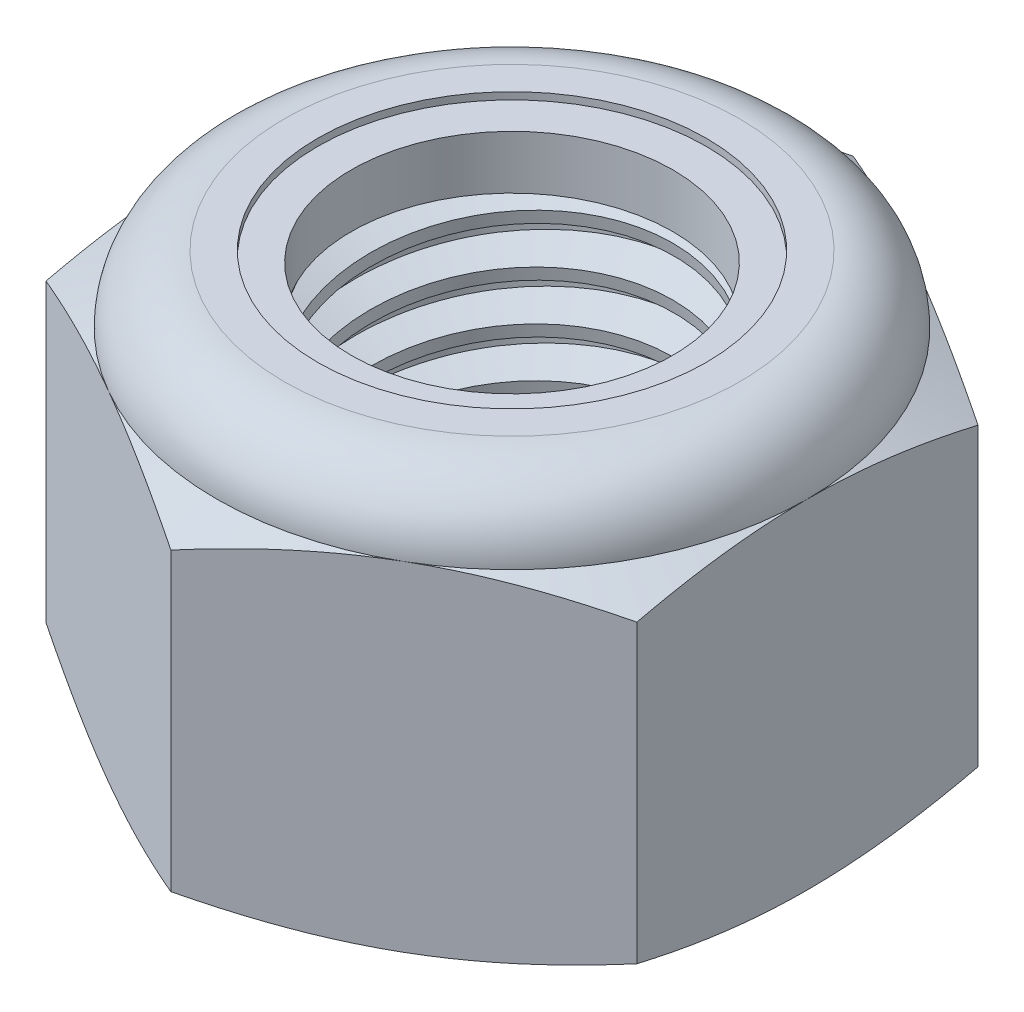
from build123d import *

# Parameters (mm, degrees)
EXTRUDE1_DEPTH      = 8.73125
SKETCH2_W           = 3.9624
SKETCH2_H           = 8.73125
LPATTERN1_COUNT     = 8
LPATTERN1_PITCH     = 1.058333333
LPATTERN1_COL_COUNT = 2
LPATTERN1_COL_PITCH = 1.058333333


with BuildPart() as part:
    # Sketch1 → Extrude1 (new body)
    with BuildSketch(Plane(origin=(0, 0, 0), x_dir=(1, 0, 0), z_dir=(0, 1, 0))):
        Polygon((0, 7.332348419), (-6.35, 3.666174209), (-6.35, -3.666174209), (0, -7.332348419), (6.35, -3.666174209), (6.35, 3.666174209), align=None)
    extrude(amount=EXTRUDE1_DEPTH)

    # Sketch4 → Cut-Revolve2 (revolve, cut)
    with BuildSketch(Plane(origin=(0, 0, 0), x_dir=(0, 0, -1), z_dir=(1, 0, 0))):
        Polygon((0, 8.73125), (3.9624, 8.73125), (3.4558921, 8.495061487), (3.4558921, 0.236188513), (3.9624, 0), (0, 0), align=None)
    revolve(axis=Axis((0, 8.73125, 0), (0, 1, 0)), mode=Mode.SUBTRACT)


with BuildPart() as body_2:
    # Sketch2 → Revolve1 (revolve)
    with BuildSketch(Plane(origin=(0, 0, 0), x_dir=(0, 0, -1), z_dir=(1, 0, 0))):
        with Locations((1.9812, 4.365625)):
            Rectangle(SKETCH2_W, SKETCH2_H)
    revolve(axis=Axis((0, -3.9624, 0), (0, 1, 0)))

    # Sketch3 → Cut-Revolve1 (revolve, cut)
    with BuildSketch(Plane(origin=(0, 0, 0), x_dir=(0, 0, -1), z_dir=(1, 0, 0))):
        Polygon((3.979911688, 8.600122482), (4.102493502, 7.682229859), (3.490915476, 7.934220821), (3.4558921, 8.196475856), align=None)
    cut_revolve1 = revolve(axis=Axis((0, 8.73125, 0.150876649), (0, -0.991200133, -0.132371813)), mode=Mode.SUBTRACT)

    # LPattern1: Cut-Revolve1 ×8
    with Locations(*[(0, -i * LPATTERN1_PITCH, 0) for i in range(1, LPATTERN1_COUNT)]):
        add(cut_revolve1, mode=Mode.SUBTRACT)

    # LPattern1 col: Cut-Revolve1 ×2
    with Locations(*[(0, i * LPATTERN1_COL_PITCH, 0) for i in range(1, LPATTERN1_COL_COUNT)]):
        add(cut_revolve1, mode=Mode.SUBTRACT)


with BuildPart() as part_1:
    add(part.part)

    # Combine1: cut body 2
    add(body_2.part, mode=Mode.SUBTRACT)

    # Sketch5 → Cut-Revolve3 (revolve, cut)
    with BuildSketch(Plane(origin=(0, 0, 0), x_dir=(0, 0, -1), z_dir=(1, 0, 0))):
        with BuildLine():
            Line((0, 0), (6.35, 0))
            Line((6.35, 0), (7.332348419, 0.458076591))
            Line((7.332348419, 0.458076591), (7.332348419, 6.817965076))
            Line((7.332348419, 6.817965076), (6.35, 7.276041667))
            ThreePointArc((6.35, 7.276041667), (5.923779347, 8.305029347), (4.894791667, 8.73125))
            Line((4.894791667, 8.73125), (4.894791667, 10.00125))
            Line((4.894791667, 10.00125), (8.602348419, 10.00125))
            Line((8.602348419, 10.00125), (8.602348419, -1.27))
            Line((8.602348419, -1.27), (0, -1.27))
            Line((0, -1.27), (0, 0))
        make_face()
    revolve(axis=Axis((0, 0, 0), (0, 1, 0)), mode=Mode.SUBTRACT)

    # Sketch6 → Cut-Revolve4 (revolve, cut)
    with BuildSketch(Plane(origin=(0, 0, 0), x_dir=(0, 0, -1), z_dir=(1, 0, 0))):
        with BuildLine():
            Line((0, 7.276041667), (6.1976, 7.276041667))
            ThreePointArc((6.1976, 7.276041667), (5.816016274, 8.197266274), (4.894791667, 8.57885))
            Line((4.894791667, 8.57885), (4.175341883, 8.57885))
            Line((4.175341883, 8.57885), (4.175341883, 10.00125))
            Line((4.175341883, 10.00125), (0, 10.00125))
            Line((0, 10.00125), (0, 7.276041667))
        make_face()
    revolve(axis=Axis((0, 10.00125, 0), (0, 1, 0)), mode=Mode.SUBTRACT)


with BuildPart() as body_2_2:
    # Sketch7 → Revolve2 (revolve)
    with BuildSketch(Plane(origin=(0, 0, 0), x_dir=(0, 0, -1), z_dir=(1, 0, 0))):
        with BuildLine():
            Line((3.4558921, 7.352241667), (6.119030844, 7.352241667))
            ThreePointArc((6.119030844, 7.352241667), (5.734762038, 8.169919611), (4.894791667, 8.50265))
            Line((4.894791667, 8.50265), (3.4558921, 8.50265))
            Line((3.4558921, 8.50265), (3.4558921, 7.352241667))
        make_face()
    revolve(axis=Axis((0, 7.352241667, 0), (0, 1, 0)))


solid = Compound([part_1.part, body_2_2.part])
